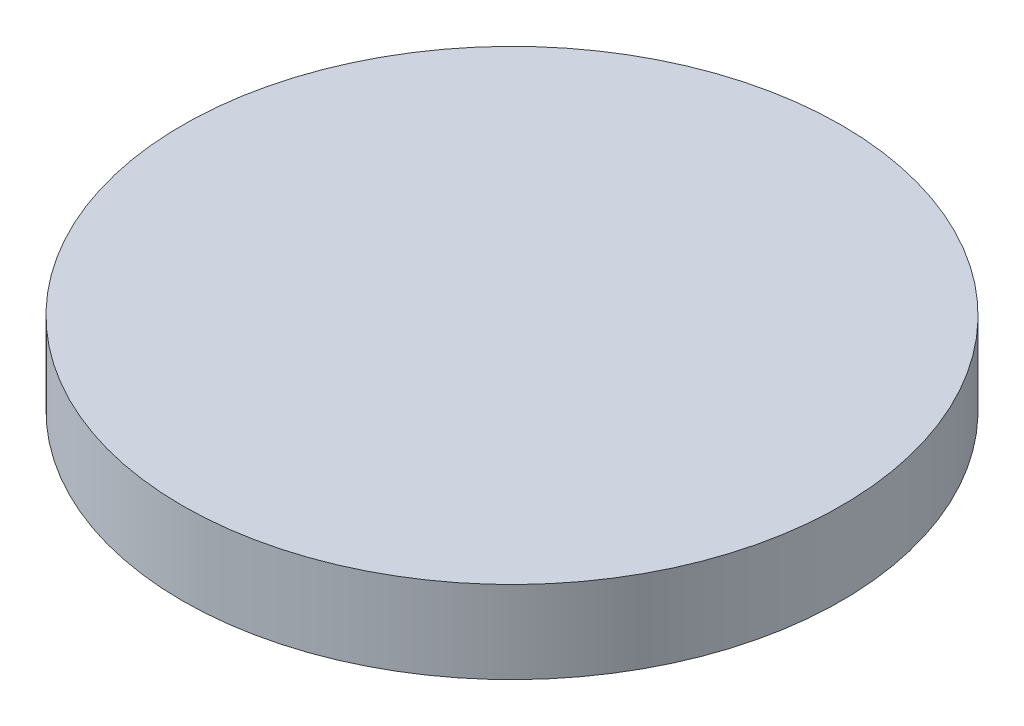
from build123d import *

# Parameters (mm, degrees)
SKETCH2_R           = 40
BOSS_EXTRUDE1_DEPTH = 10


with BuildPart() as part:
    # Sketch2 → Boss-Extrude1 (new body)
    with BuildSketch(Plane(origin=(0, 0, 0), x_dir=(1, 0, 0), z_dir=(0, 1, 0))):
        Circle(SKETCH2_R)
    extrude(amount=BOSS_EXTRUDE1_DEPTH)


solid = part.part
